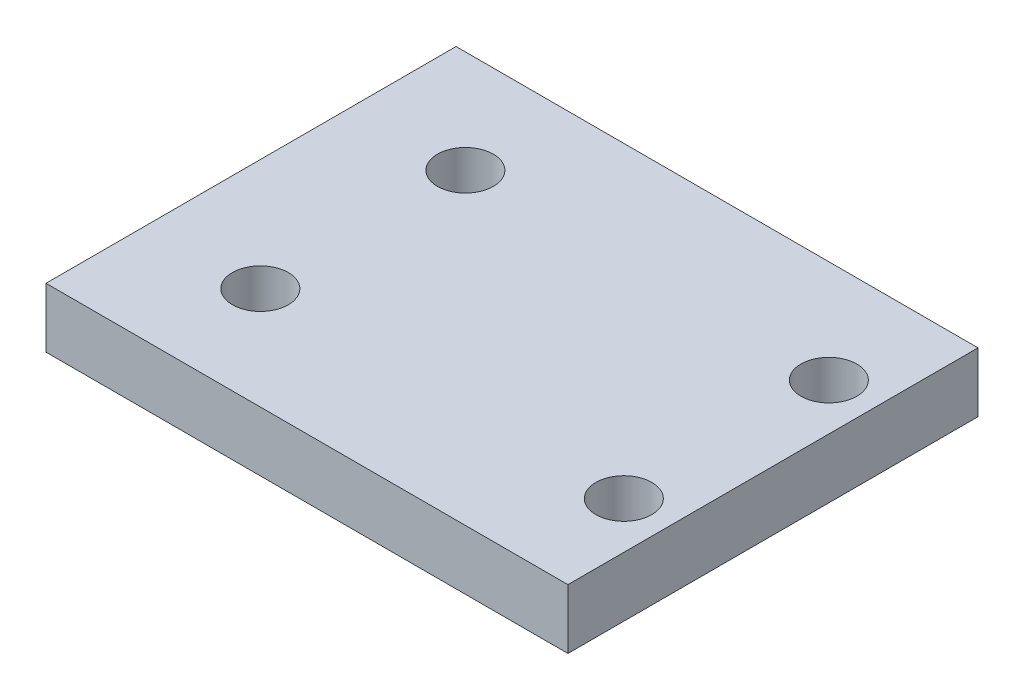
from build123d import *

# Parameters (mm, degrees)
SKETCH1_W           = 56
SKETCH1_H           = 44
SKETCH1_R           = 3
BOSS_EXTRUDE1_DEPTH = 6.4


with BuildPart() as part:
    # Sketch1 → Boss-Extrude1 (new body)
    with BuildSketch(Plane(origin=(0, 0, 0), x_dir=(1, 0, 0), z_dir=(0, 1, 0))):
        with Locations((0, 22)):
            Rectangle(SKETCH1_W, SKETCH1_H)
        with Locations((-16, 33)):
            Circle(SKETCH1_R, mode=Mode.SUBTRACT)
        with Locations((-16, 11)):
            Circle(SKETCH1_R, mode=Mode.SUBTRACT)
        with Locations((23, 33)):
            Circle(SKETCH1_R, mode=Mode.SUBTRACT)
        with Locations((23, 11)):
            Circle(SKETCH1_R, mode=Mode.SUBTRACT)
    extrude(amount=BOSS_EXTRUDE1_DEPTH)


solid = part.part
